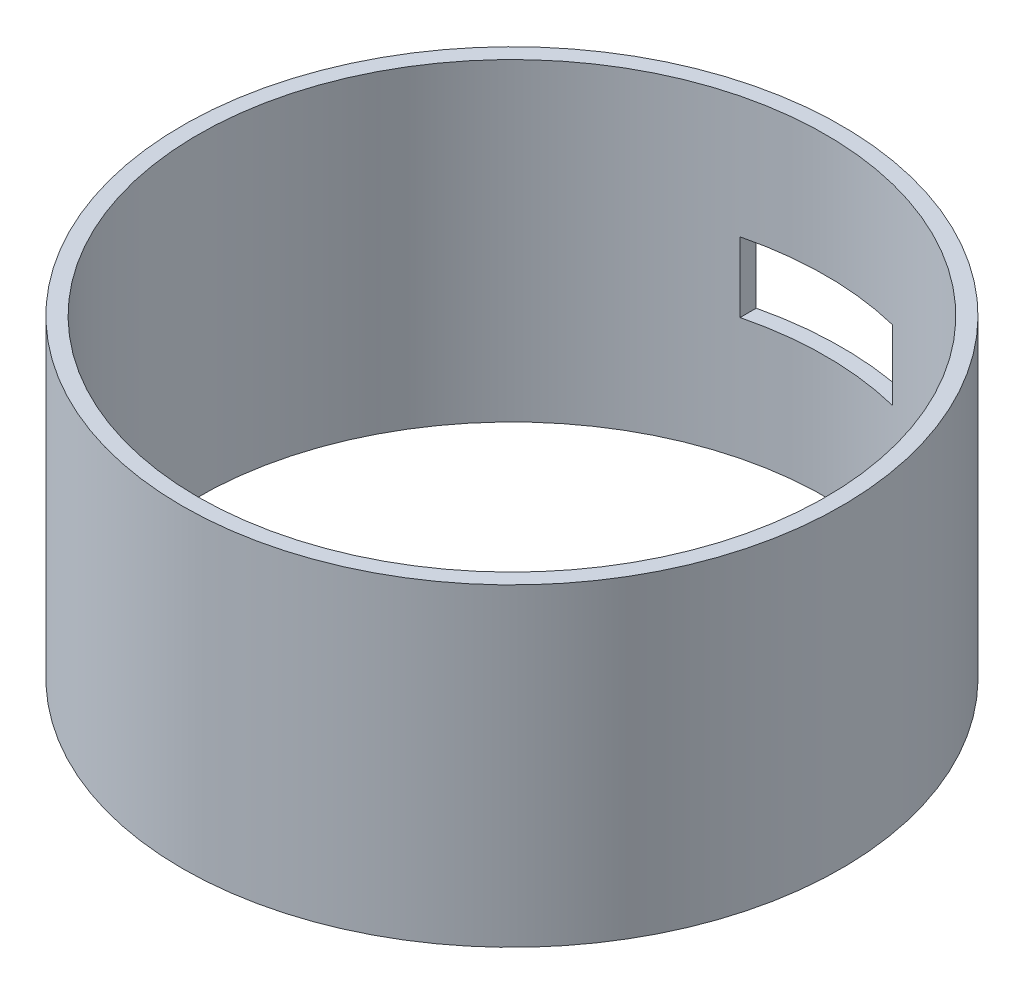
from build123d import *

# Parameters (mm, degrees)
SKETCH1_R           = 105
SKETCH1_R_2         = 100
BOSS_EXTRUDE3_DEPTH = 100
SKETCH2_W           = 48.620736816
SKETCH2_H           = 22.255971078
CUT_EXTRUDE2_DEPTH  = 187


with BuildPart() as part:
    # Sketch1 → Boss-Extrude3 (new body)
    with BuildSketch(Plane(origin=(0, 0, 0), x_dir=(1, 0, 0), z_dir=(0, 1, 0))):
        Circle(SKETCH1_R)
        Circle(SKETCH1_R_2, mode=Mode.SUBTRACT)
    extrude(amount=BOSS_EXTRUDE3_DEPTH)

    # Sketch2 → Cut-Extrude2 (cut)
    with BuildSketch(Plane.XY):
        with Locations((0, 50)):
            Rectangle(SKETCH2_W, SKETCH2_H)
    extrude(amount=-CUT_EXTRUDE2_DEPTH, mode=Mode.SUBTRACT)


solid = part.part
